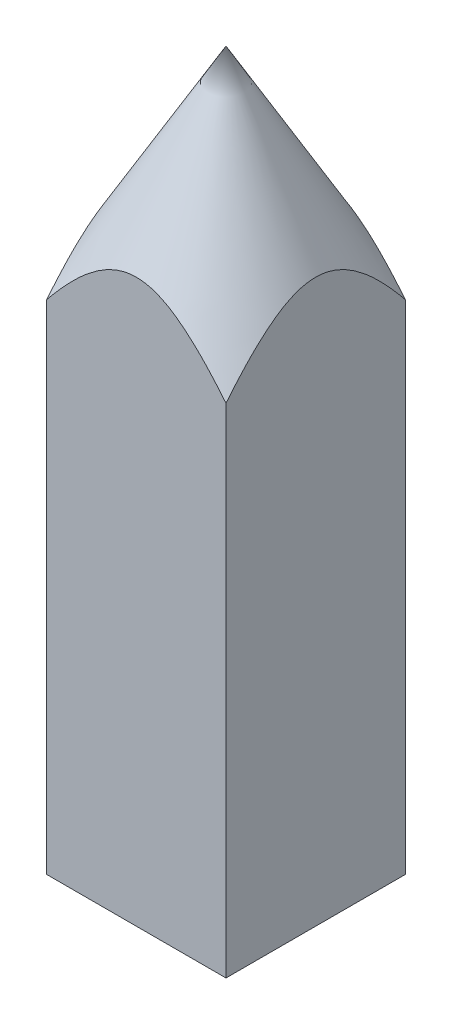
from build123d import *

# Parameters (mm, degrees)
SKETCH5_OUTSIDE_W   = 25.086
SKETCH5_OUTSIDE_H   = 25.086
SKETCH5_OUTSIDE_W_2 = 10
SKETCH5_OUTSIDE_H_2 = 10
EXTRUDE2_DEPTH      = 41


with BuildPart() as part:
    # Sketch4 → Revolve1 (revolve)
    with BuildSketch(Plane.XY, mode=Mode.PRIVATE) as revolve1_sk:
        Polygon((0, 0), (0, 40), (7.071067812, 27.752551286), (7.071067812, 0), align=None)
    revolve(revolve1_sk.sketch.rotate(Axis((0, 0, 0), (0, 1, 0)), 90), axis=Axis((0, 0, 0), (0, 1, 0)))  # turned: the seam where the file's is

    # Sketch5 outside → Extrude2 (cut, through all)
    with BuildSketch(Plane(origin=(0, 0, 0), x_dir=(1, 0, 0), z_dir=(0, 1, 0))):
        Rectangle(SKETCH5_OUTSIDE_W, SKETCH5_OUTSIDE_H)
        Rectangle(SKETCH5_OUTSIDE_W_2, SKETCH5_OUTSIDE_H_2, mode=Mode.SUBTRACT)
    extrude(amount=EXTRUDE2_DEPTH, mode=Mode.SUBTRACT)


solid = part.part
